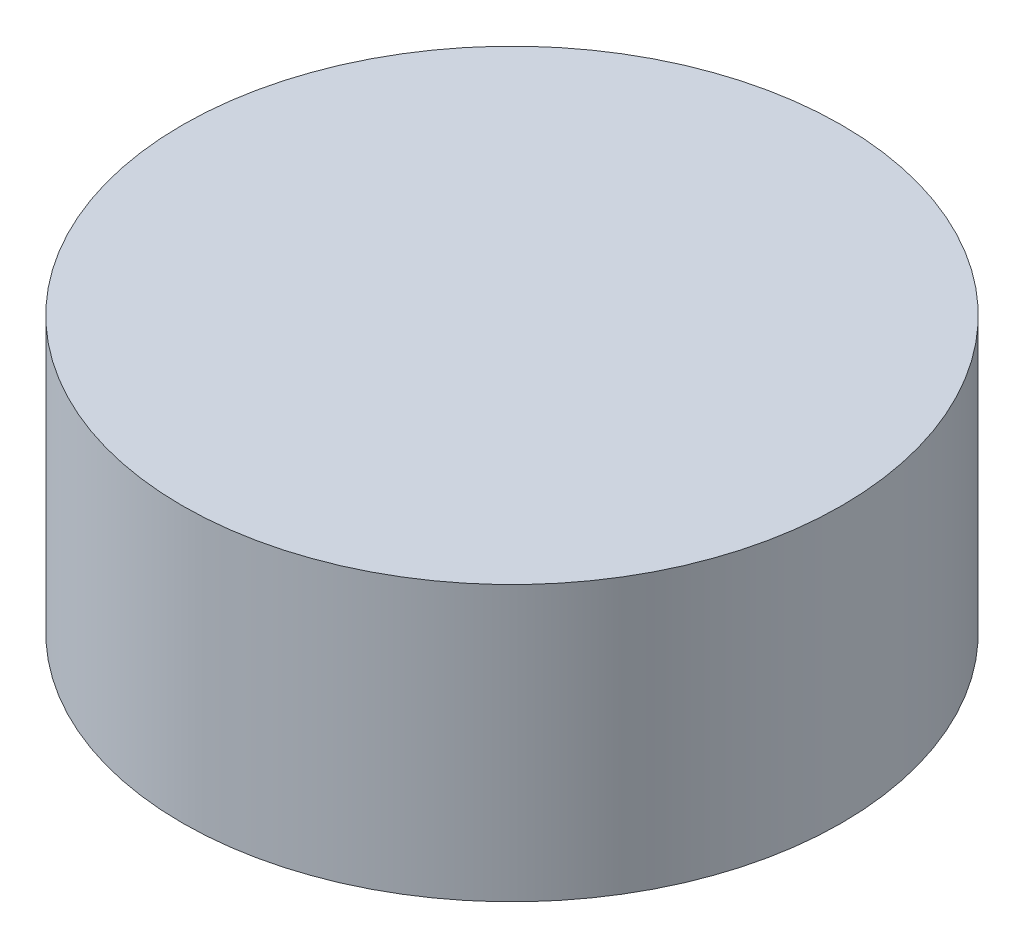
from build123d import *

# Parameters (mm, degrees)
SKETCH1_R           = 30
BOSS_EXTRUDE1_DEPTH = 25


with BuildPart() as part:
    # Sketch1 → Boss-Extrude1 (new body)
    with BuildSketch(Plane(origin=(0, 0, 0), x_dir=(1, 0, 0), z_dir=(0, 1, 0))):
        Circle(SKETCH1_R)
    extrude(amount=BOSS_EXTRUDE1_DEPTH)


solid = part.part
